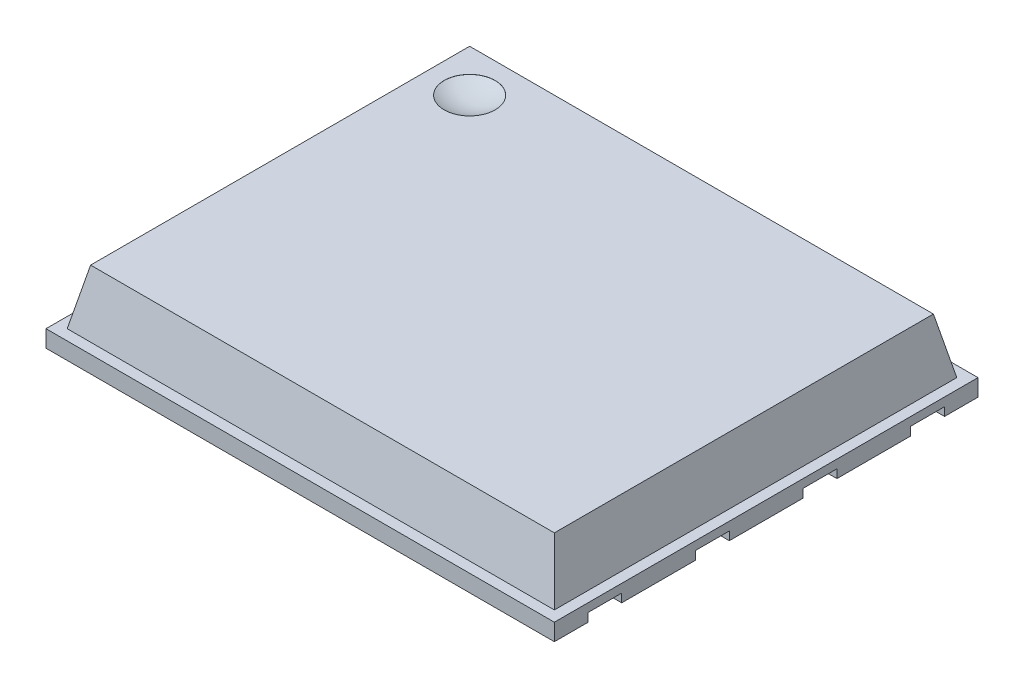
from build123d import *

# Parameters (mm, degrees)
SKETCH1_W         = 6
SKETCH1_H         = 5
EXTRUDE1_DEPTH    = 0.2
SKETCH2_W         = 5.75
SKETCH2_H         = 4.75
EXTRUDE2_DEPTH    = 0.65
EXTRUDE2_TAPER    = 12
SKETCH3_R         = 0.30087537
EXTRUDE3_DEPTH    = 0.001
DOME1_FACE_RADIUS = 0.30087537
DOME1_HEIGHT      = 0.075
EXTRUDE4_DEPTH    = 0.1
FILLET1_R         = 0.1
EXTRUDE5_DEPTH    = 0.1


with BuildPart() as part:
    # Sketch1 → Extrude1 (new body)
    with BuildSketch(Plane(origin=(0, 0, 0), x_dir=(1, 0, 0), z_dir=(0, 1, 0))):
        Rectangle(SKETCH1_W, SKETCH1_H)
    extrude(amount=EXTRUDE1_DEPTH)

    # Sketch2 → Extrude2 (add)
    with BuildSketch(Plane(origin=(0, 0.2, 0), x_dir=(-1, 0, 0), z_dir=(0, 1, 0))):
        Rectangle(SKETCH2_W, SKETCH2_H)
    extrude(amount=EXTRUDE2_DEPTH, taper=EXTRUDE2_TAPER)

    # Sketch3 → Extrude3 (cut)
    with BuildSketch(Plane(origin=(0, 0.85, 0), x_dir=(-1, 0, 0), z_dir=(0, 1, 0))):
        with Locations((2.236838235, -1.736838235)):
            Circle(SKETCH3_R)
    extrude(amount=-EXTRUDE3_DEPTH, mode=Mode.SUBTRACT)

    # Dome1: a dome of height H over a round flat face of radius A is a cap of a sphere of radius (A * A + H * H) / (2 * H)
    dome1_r = (DOME1_FACE_RADIUS * DOME1_FACE_RADIUS + DOME1_HEIGHT * DOME1_HEIGHT) / (2 * DOME1_HEIGHT)
    dome1_base = Plane((-2.236838235, 0.849, -1.736838235), z_dir=(0, -1, 0))
    with Locations(dome1_base.offset(DOME1_HEIGHT - dome1_r)):
        dome1_ball = Sphere(dome1_r, mode=Mode.PRIVATE)
    add(split(dome1_ball, bisect_by=dome1_base, keep=Keep.TOP, mode=Mode.PRIVATE), mode=Mode.SUBTRACT)

    # Sketch4 → Extrude4 (cut)
    with BuildSketch(Plane.XZ):
        with BuildLine():
            Line((-1.7, -1.68154059), (-1.7, -2))
            Line((-1.7, -2), (1.7, -2))
            Line((1.7, -2), (1.7, 2))
            Line((1.7, 2), (-1.7, 2))
            Line((-1.7, 2), (-1.7, -1.386002452))
            ThreePointArc((-1.7, -1.386002452), (-1.552230931, -1.533771521), (-1.7, -1.68154059))
        make_face()
    extrude(amount=-EXTRUDE4_DEPTH, mode=Mode.SUBTRACT)

    # Fillet1
    fillet1_edges = [part.edges().sort_by_distance(p)[0] for p in [
        (1.7, 0.05, 2),
        (1.7, 0.05, -2),
        (-1.7, 0.05, -2),
        (-1.7, 0.05, -1.68154059),
        (-1.7, 0.05, -1.386002452),
        (-1.7, 0.05, 2),
    ]]
    fillet(fillet1_edges, radius=FILLET1_R)

    # Sketch5 → Extrude5 (cut)
    with BuildSketch(Plane.XZ):
        with BuildLine():
            Line((3, 2.105), (2.6, 2.105))
            ThreePointArc((2.6, 2.105), (2.4, 1.905), (2.6, 1.705))
            Line((2.6, 1.705), (3, 1.705))
            Line((3, 1.705), (3, 2.105))
        make_face()
        with BuildLine():
            Line((3, 0.435), (2.6, 0.435))
            ThreePointArc((2.6, 0.435), (2.4, 0.635), (2.6, 0.835))
            Line((2.6, 0.835), (3, 0.835))
            Line((3, 0.835), (3, 0.435))
        make_face()
        with BuildLine():
            Line((3, -0.835), (2.6, -0.835))
            ThreePointArc((2.6, -0.835), (2.4, -0.635), (2.6, -0.435))
            Line((2.6, -0.435), (3, -0.435))
            Line((3, -0.435), (3, -0.835))
        make_face()
        with BuildLine():
            Line((3, -2.105), (2.6, -2.105))
            ThreePointArc((2.6, -2.105), (2.4, -1.905), (2.6, -1.705))
            Line((2.6, -1.705), (3, -1.705))
            Line((3, -1.705), (3, -2.105))
        make_face()
    extrude5 = extrude(amount=-EXTRUDE5_DEPTH, mode=Mode.SUBTRACT)

    # Mirror1: Extrude5 across plane
    add(extrude5.mirror(Plane(origin=(0, 0, 0), x_dir=(0, 0, 1), z_dir=(1, 0, 0))), mode=Mode.SUBTRACT)


solid = part.part
